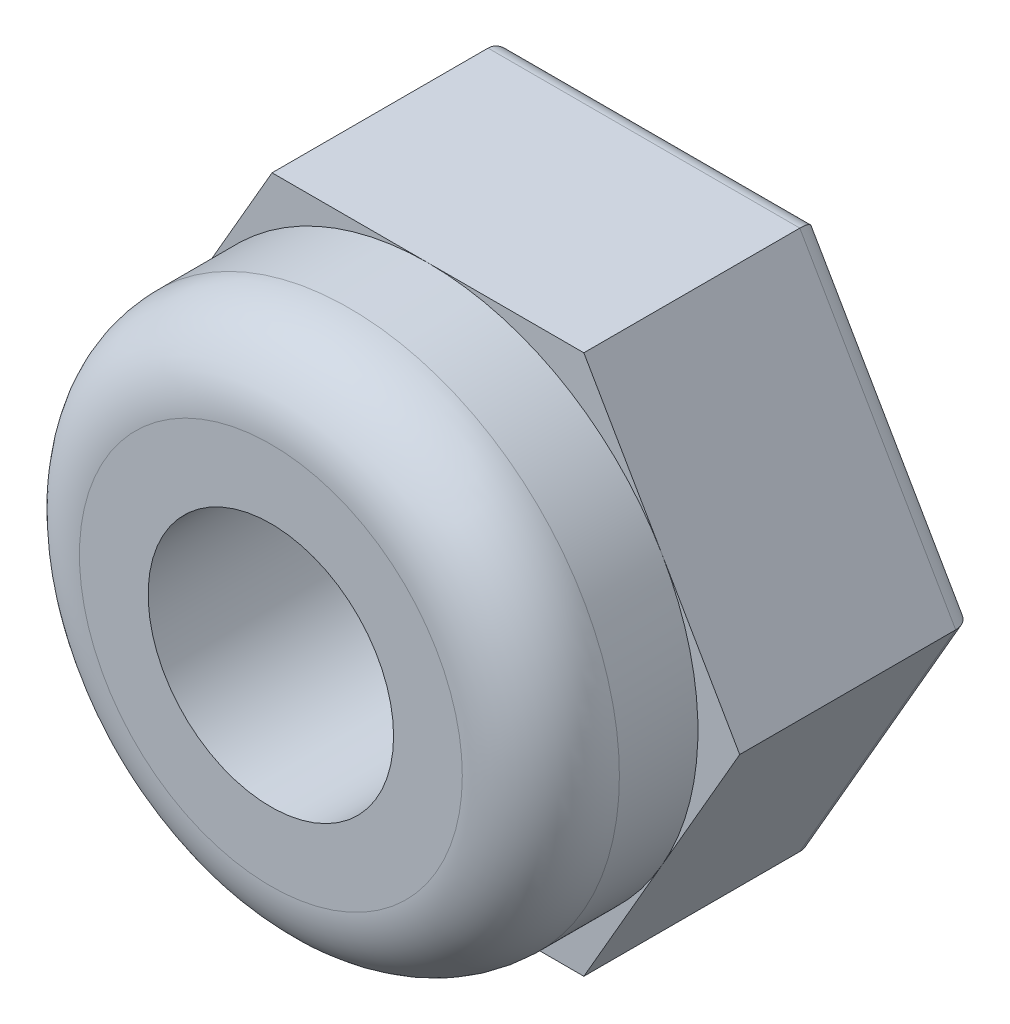
from build123d import *

# Parameters (mm, degrees)
SKETCH1_R           = 1.25
BOSS_EXTRUDE1_DEPTH = 2.4
SKETCH2_R           = 2.75
SKETCH2_R_2         = 1.25
BOSS_EXTRUDE2_DEPTH = 1.6
FILLET1_R           = 0.2
FILLET2_R           = 0.8


with BuildPart() as part:
    # Sketch1 → Boss-Extrude1 (new body)
    with BuildSketch(Plane.XY):
        Polygon((3.175426481, 0), (1.58771324, 2.75), (-1.58771324, 2.75), (-3.175426481, 0), (-1.58771324, -2.75), (1.58771324, -2.75), align=None)
        Circle(SKETCH1_R, mode=Mode.SUBTRACT)
    extrude(amount=BOSS_EXTRUDE1_DEPTH)

    # Sketch2 → Boss-Extrude2 (add)
    with BuildSketch(Plane.XY.offset(2.4)):
        Circle(SKETCH2_R)
        Circle(SKETCH2_R_2, mode=Mode.SUBTRACT)
    extrude(amount=BOSS_EXTRUDE2_DEPTH)

    # Fillet1
    fillet1_edges = [part.edges().sort_by_distance(p)[0] for p in [
        (-1.25, 0, 0),
        (0, -2.75, 0),
        (-2.38156986, -1.375, 0),
        (-2.38156986, 1.375, 0),
        (0, 2.75, 0),
        (2.38156986, 1.375, 0),
        (2.38156986, -1.375, 0),
    ]]
    fillet(fillet1_edges, radius=FILLET1_R)

    # Fillet2
    fillet2_edges = [part.edges().sort_by_distance(p)[0] for p in [
        (-2.75, 0, 4),
    ]]
    fillet(fillet2_edges, radius=FILLET2_R)


solid = part.part
